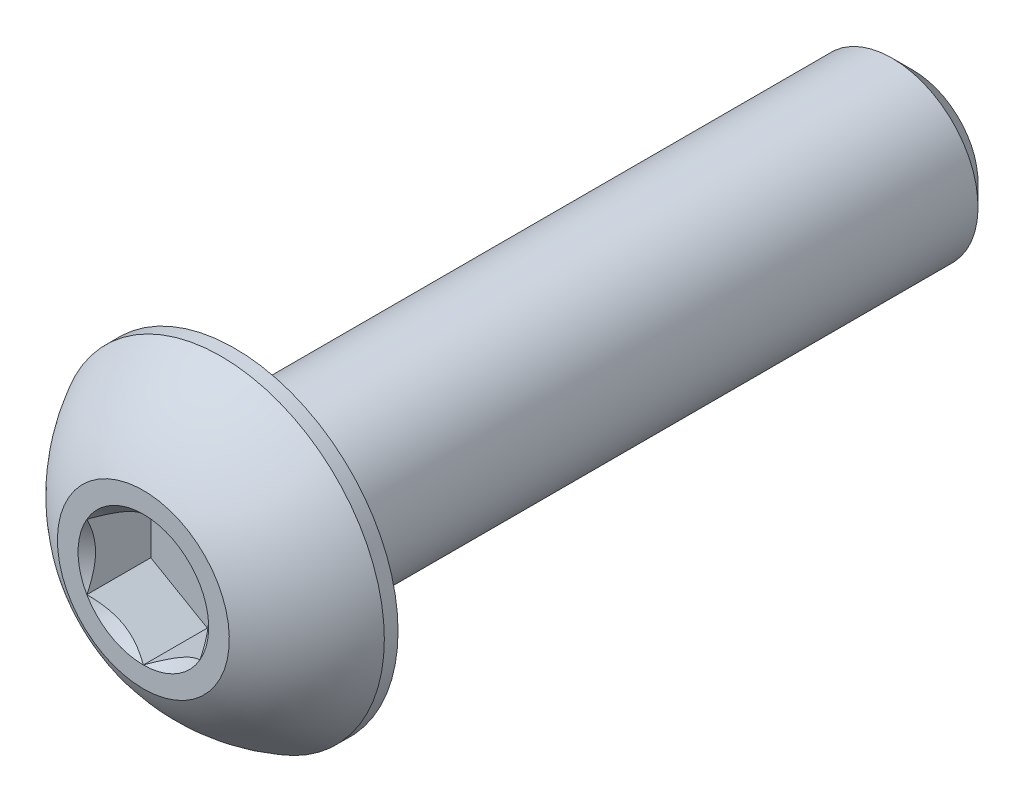
from build123d import *

# Parameters (mm, degrees)
SKETCH1_W          = 19.05
SKETCH1_H          = 2.413
CHAMFER1_SIZE      = 0.5953125
CUT_EXTRUDE2_DEPTH = 1.79578
SKETCH6_R          = 1.833087105
CUT_EXTRUDE3_DEPTH = 1.79578
CUT_EXTRUDE3_TAPER = 45


with BuildPart() as part:
    # Sketch1 → Revolve1 (revolve)
    with BuildSketch(Plane(origin=(0, 0, 0), x_dir=(0, 0, -1), z_dir=(1, 0, 0))):
        with Locations((12.0904, 1.2065)):
            Rectangle(SKETCH1_W, SKETCH1_H)
    revolve(axis=Axis((0, 0, -21.6154), (0, 0, 1)))

    # Chamfer1
    chamfer1_edges = [part.edges().sort_by_distance(p)[0] for p in [
        (0, -2.413, -21.6154),
    ]]
    chamfer(chamfer1_edges, length=CHAMFER1_SIZE)

    # Sketch7 → Revolve2 (revolve)
    with BuildSketch(Plane(origin=(0, 0, 0), x_dir=(0, 0, -1), z_dir=(1, 0, 0))):
        with BuildLine():
            Line((2.18059, 4.5847), (2.5654, 4.5847))
            Line((2.5654, 4.5847), (2.5654, 0))
            Line((2.5654, 0), (0, 0))
            Line((0, 0), (0, 2.413))
            ThreePointArc((0, 2.413), (0.925030326, 3.664791196), (2.18059, 4.5847))
        make_face()
    revolve(axis=Axis((0, 0, 0), (0, 0, -1)))

    # Sketch5 → Cut-Extrude2 (cut)
    with BuildSketch(Plane.XY):
        Polygon((1.5875, -0.916543552), (1.5875, 0.916543552), (0, 1.833087105), (-1.5875, 0.916543552), (-1.5875, -0.916543552), (0, -1.833087105), align=None)
    extrude(amount=-CUT_EXTRUDE2_DEPTH, mode=Mode.SUBTRACT)

    # Sketch6 → Cut-Extrude3 (cut)
    with BuildSketch(Plane.XY):
        Circle(SKETCH6_R)
    extrude(amount=-CUT_EXTRUDE3_DEPTH, taper=CUT_EXTRUDE3_TAPER, mode=Mode.SUBTRACT)


solid = part.part
